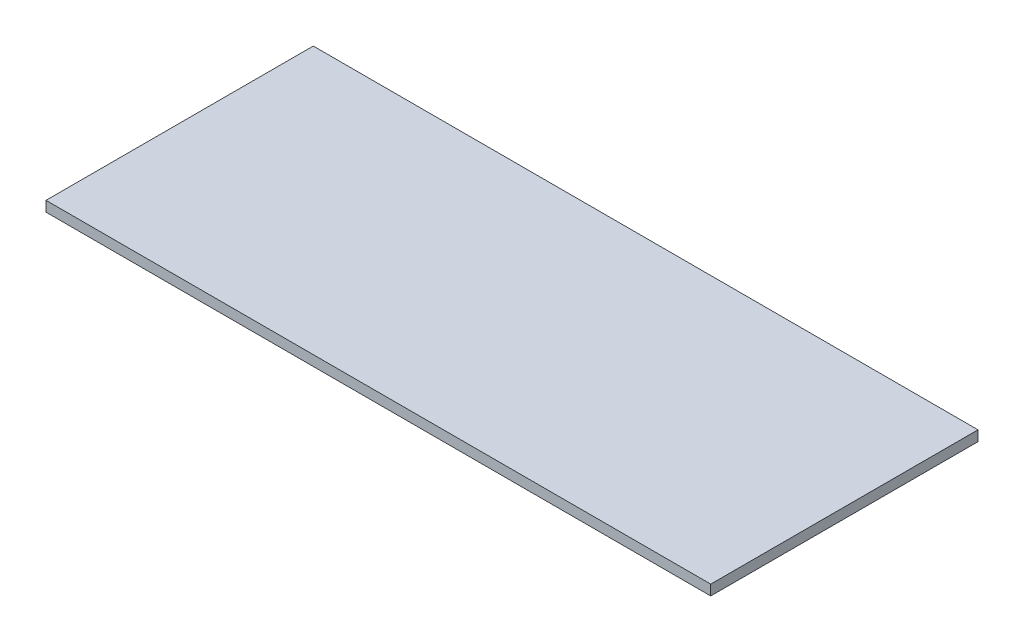
from build123d import *

# Parameters (mm, degrees)
SKETCH1_W           = 194
SKETCH1_H           = 78
BOSS_EXTRUDE1_DEPTH = 3


with BuildPart() as part:
    # Sketch1 → Boss-Extrude1 (new body)
    with BuildSketch(Plane(origin=(0, 0, 0), x_dir=(1, 0, 0), z_dir=(0, 1, 0))):
        Rectangle(SKETCH1_W, SKETCH1_H)
    extrude(amount=BOSS_EXTRUDE1_DEPTH)


solid = part.part
